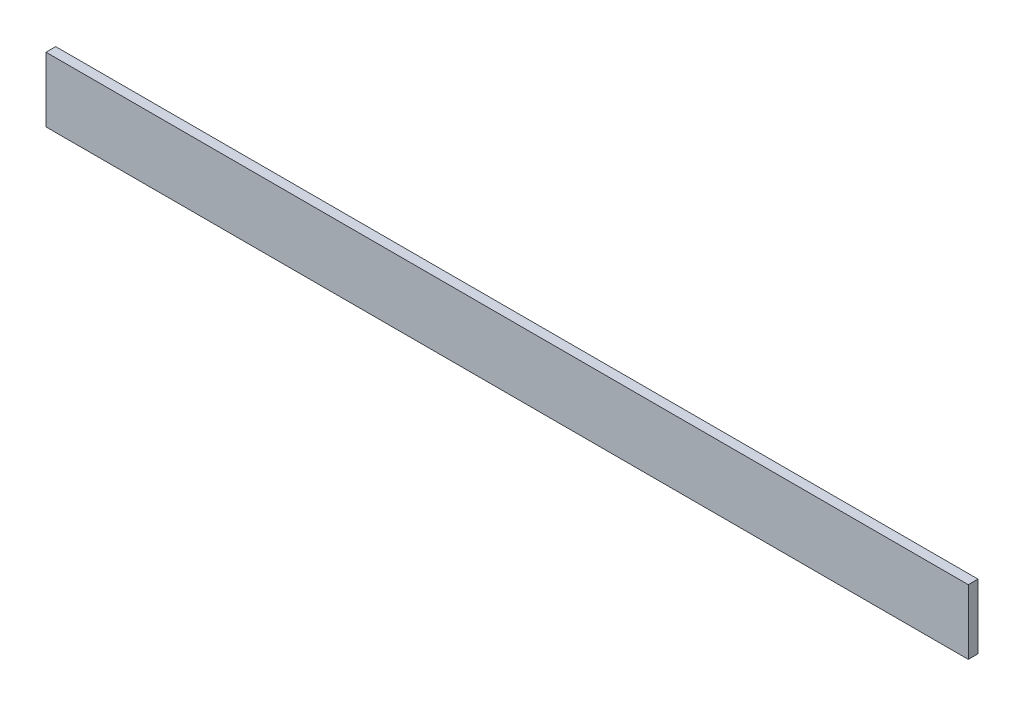
from build123d import *

# Parameters (mm, degrees)
SKETCH1_W           = 285
SKETCH1_H           = 20
BOSS_EXTRUDE1_DEPTH = 3


with BuildPart() as part:
    # Sketch1 → Boss-Extrude1 (new body)
    with BuildSketch(Plane(origin=(0, 0, -67.5), x_dir=(-1, 0, 0), z_dir=(0, 0, -1))):
        with Locations((0, 13)):
            Rectangle(SKETCH1_W, SKETCH1_H)
    extrude(amount=BOSS_EXTRUDE1_DEPTH)


solid = part.part
